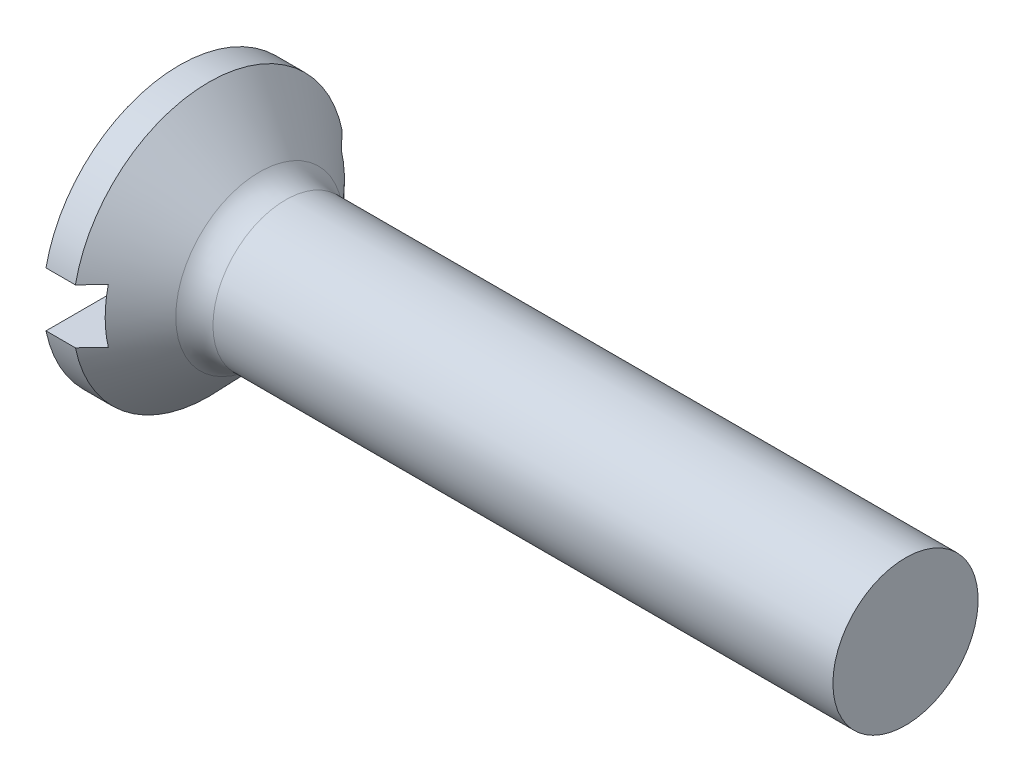
from build123d import *

# Parameters (mm, degrees)
FILLET1_R  = 0.4
SLOTSKE_W  = 3
SLOTSKE_H  = 0.6
SLOT_DEPTH = 0.5


with BuildPart() as part:
    # BodySke → BaseBody (revolve)
    with BuildSketch(Plane.XY):
        Polygon((0, 0), (0, 1.5), (0.324017858, 1.5), (1, 0.8), (8, 0.8), (8, 0), align=None)
    revolve(axis=Axis((0, 0, 0), (1, 0, 0)))

    # Fillet1
    fillet1_edges = [part.edges().sort_by_distance(p)[0] for p in [
        (1, -0.8, 0),
    ]]
    fillet(fillet1_edges, radius=FILLET1_R)

    # SlotSke → Slot (cut)
    with BuildSketch(Plane.ZY):
        Rectangle(SLOTSKE_W, SLOTSKE_H)
    extrude(amount=-SLOT_DEPTH, mode=Mode.SUBTRACT)


solid = part.part
